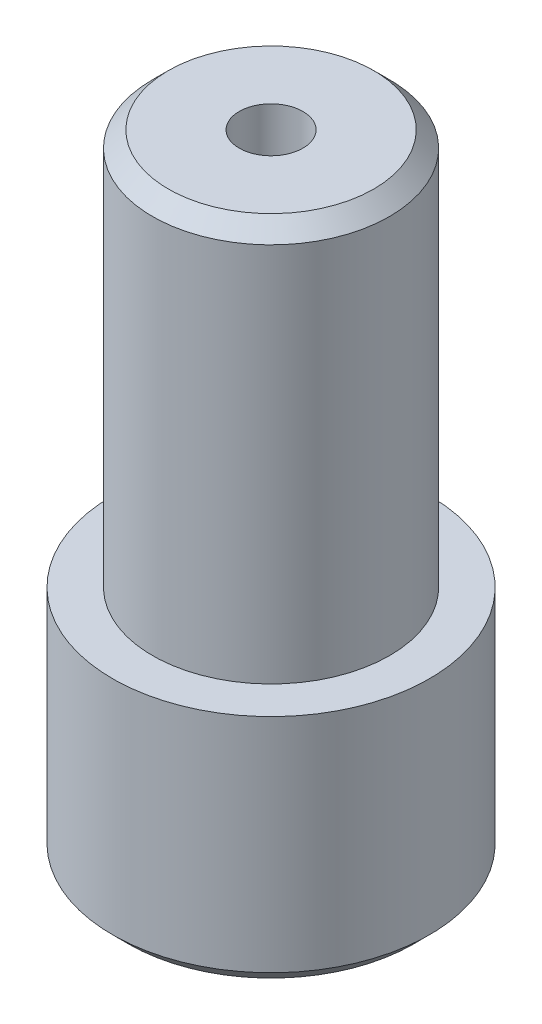
from build123d import *

# Parameters (mm, degrees)
CHAMFER1_SIZE               = 1.27
F_1_4_20_TAPPED_HOLE1_D     = 5.1054
F_1_4_20_TAPPED_HOLE1_DEPTH = 16.51
F_1_4_20_TAPPED_HOLE1_TIP   = 1.533816902


with BuildPart() as part:
    # Sketch1 → Revolve1 (revolve)
    with BuildSketch(Plane.XY):
        Polygon((0, 0), (12.7, 0), (12.7, 19.05), (9.4996, 19.05), (9.4996, 50.8), (0, 50.8), align=None)
    revolve(axis=Axis((0, 50.8, 0), (0, -1, 0)))

    # Chamfer1
    chamfer1_edges = [part.edges().sort_by_distance(p)[0] for p in [
        (-9.4996, 50.8, 0),
        (-12.7, 0, 0),
    ]]
    chamfer(chamfer1_edges, length=CHAMFER1_SIZE)

    # 1/4-20 Tapped Hole1
    with Locations(Plane(origin=(0, 50.8, 0), x_dir=(1, 0, 0), z_dir=(0, 1, 0))):
        with Locations((0, 0)):
            Hole(F_1_4_20_TAPPED_HOLE1_D / 2, depth=F_1_4_20_TAPPED_HOLE1_DEPTH)
            with Locations((0, 0, -(F_1_4_20_TAPPED_HOLE1_DEPTH + F_1_4_20_TAPPED_HOLE1_TIP / 2))):  # 118° drill point
                Cone(0, F_1_4_20_TAPPED_HOLE1_D / 2, F_1_4_20_TAPPED_HOLE1_TIP, mode=Mode.SUBTRACT)


solid = part.part
